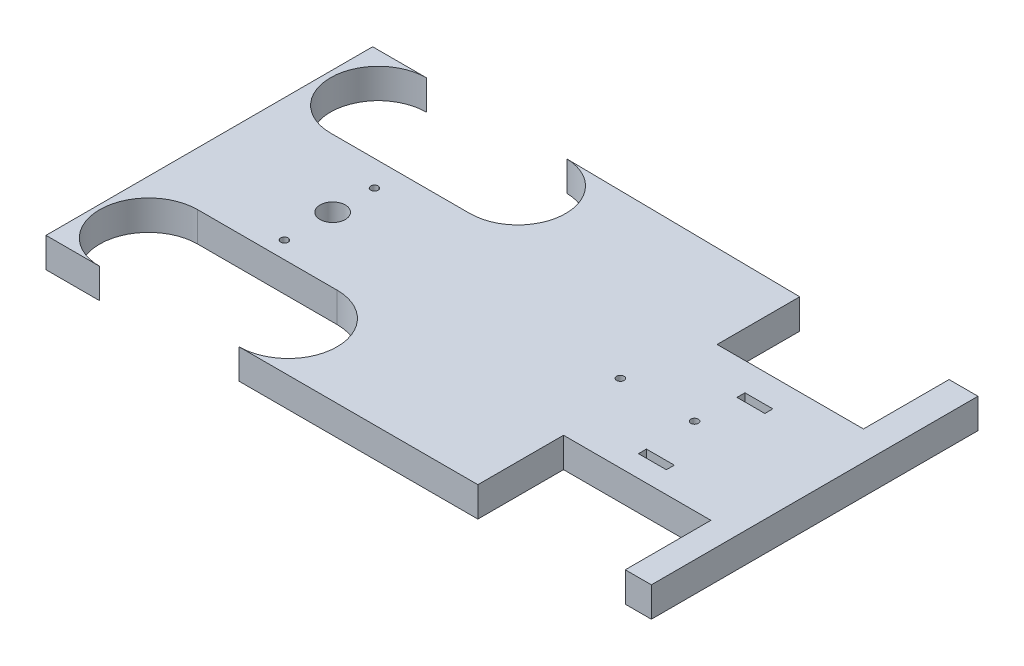
from build123d import *

# Parameters (mm, degrees)
SKETCH1_R           = 0.5
SKETCH1_R_2         = 1.695720035
SKETCH1_W           = 3.739481929
SKETCH1_H           = 1.068423409
SKETCH1_W_2         = 3.73948193
BOSS_EXTRUDE1_DEPTH = 4


with BuildPart() as part:
    # Sketch1 → Boss-Extrude1 (new body)
    with BuildSketch(Plane(origin=(0, 0, 0), x_dir=(1, 0, 0), z_dir=(0, 1, 0))):
        with BuildLine():
            Line((43.455785529, -19.365174275), (43.455785529, 24.440185465))
            Line((43.455785529, 24.440185465), (39.576612996, 24.440185465))
            Line((39.576612996, 24.440185465), (39.576612996, 12.960768953))
            Line((39.576612996, 12.960768953), (19.950470546, 12.960768953))
            Line((19.950470546, 12.960768953), (19.950470546, 24.039526687))
            Line((19.950470546, 24.039526687), (-11.673190701, 24.438144265))
            ThreePointArc((-11.673190701, 24.438144265), (-5.411187986, 17.934763274), (-11.83512585, 11.591289096))
            Line((-11.83512585, 11.591289096), (-30.532535496, 11.591289096))
            ThreePointArc((-30.532535496, 11.591289096), (-36.95698368, 18.01573728), (-30.532535496, 24.440185465))
            Line((-30.532535496, 24.440185465), (-37.72291673, 24.440185465))
            Line((-37.72291673, 24.440185465), (-37.72291673, -19.365174275))
            Line((-37.72291673, -19.365174275), (-30.532535496, -19.365174275))
            ThreePointArc((-30.532535496, -19.365174275), (-37.109148108, -12.788561662), (-30.532535496, -6.21194905))
            Line((-30.532535496, -6.21194905), (-11.83512585, -6.21194905))
            ThreePointArc((-11.83512585, -6.21194905), (-5.258513237, -12.788561662), (-11.83512585, -19.365174275))
            Line((-11.83512585, -19.365174275), (20.193370142, -19.365174275))
            Line((20.193370142, -19.365174275), (20.193370142, -7.879622636))
            Line((20.193370142, -7.879622636), (39.959203195, -7.879622636))
            Line((39.959203195, -7.879622636), (39.959203195, -19.365174275))
            Line((39.959203195, -19.365174275), (43.455785529, -19.365174275))
        make_face()
        with Locations((-21.183830673, -3.926210212)):
            Circle(SKETCH1_R, mode=Mode.SUBTRACT)
        with Locations((-21.183830673, 2.537505595)):
            Circle(SKETCH1_R_2, mode=Mode.SUBTRACT)
        with Locations((17.397892673, 2.537505595)):
            Circle(SKETCH1_R, mode=Mode.SUBTRACT)
        with Locations((29.229431853, -4.460421917)):
            Rectangle(SKETCH1_W, SKETCH1_H, mode=Mode.SUBTRACT)
        with Locations((27.359690888, 2.537505595)):
            Circle(SKETCH1_R, mode=Mode.SUBTRACT)
        with Locations((-21.183830673, 8.146728488)):
            Circle(SKETCH1_R, mode=Mode.SUBTRACT)
        with Locations((29.299175369, 8.680940192)):
            Rectangle(SKETCH1_W_2, SKETCH1_H, mode=Mode.SUBTRACT)
    extrude(amount=BOSS_EXTRUDE1_DEPTH)


solid = part.part
